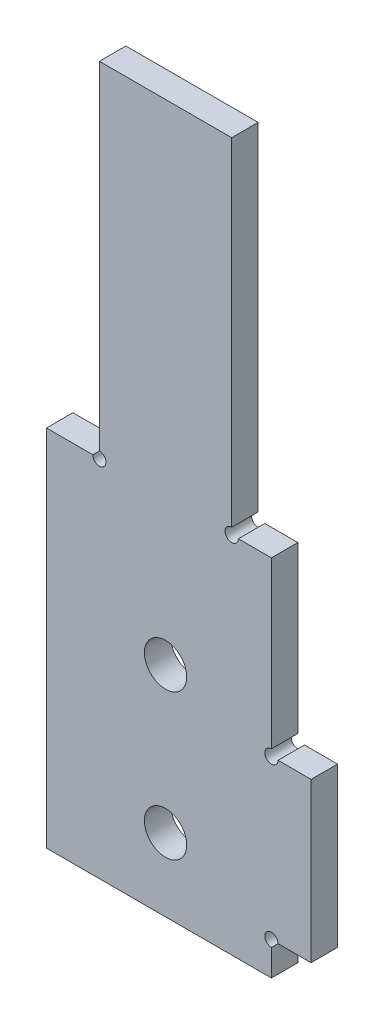
from build123d import *

# Parameters (mm, degrees)
EXTRUDE_1_DEPTH     = 2
SKETCH_2_R          = 1.6
CUT_EXTRUDE_1_DEPTH = 3
SKETCH_3_W          = 3
SKETCH_3_H          = 24
SKETCH_3_W_2        = 4
CUT_EXTRUDE_2_DEPTH = 3
SKETCH_4_W          = 10
SKETCH_4_H          = 2
EXTRUDE_2_DEPTH     = 2
SKETCH_5_R          = 0.5
CUT_EXTRUDE_3_DEPTH = 2
SKETCH_6_R          = 0.5
CUT_EXTRUDE_4_DEPTH = 2


with BuildPart() as part:
    # 草图1 → 凸台-拉伸1 (new body)
    with BuildSketch(Plane.XY):
        Polygon((0, 0), (17, 0), (17, 2.5), (20, 2.5), (20, 14.5), (17, 14.5), (17, 51.5), (0, 51.5), align=None)
    extrude(amount=EXTRUDE_1_DEPTH)

    # 草图2 → 切除-拉伸1 (cut, through all)
    with BuildSketch(Plane.XY.offset(2)):
        with Locations((9, 5.5)):
            Circle(SKETCH_2_R)
        with Locations((9, 16.5)):
            Circle(SKETCH_2_R)
    extrude(amount=-CUT_EXTRUDE_1_DEPTH, mode=Mode.SUBTRACT)

    # 草图3 → 切除-拉伸2 (cut, through all)
    with BuildSketch(Plane.XY.offset(2)):
        with Locations((15.5, 39.5)):
            Rectangle(SKETCH_3_W, SKETCH_3_H)
        with Locations((2, 39.5)):
            Rectangle(SKETCH_3_W_2, SKETCH_3_H)
    extrude(amount=-CUT_EXTRUDE_2_DEPTH, mode=Mode.SUBTRACT)

    # 草图4 → 凸台-拉伸2 (add)
    with BuildSketch(Plane(origin=(0, 51.5, 0), x_dir=(1, 0, 0), z_dir=(0, 1, 0))):
        with Locations((9, -1)):
            Rectangle(SKETCH_4_W, SKETCH_4_H)
    extrude(amount=EXTRUDE_2_DEPTH)

    # 草图5 → 切除-拉伸3 (cut)
    with BuildSketch(Plane(origin=(0, 0, 0), x_dir=(-1, 0, 0), z_dir=(0, 0, -1))):
        with Locations((-14, 27.5)):
            Circle(SKETCH_5_R)
        with Locations((-4, 27.5)):
            Circle(SKETCH_5_R)
    extrude(amount=-CUT_EXTRUDE_3_DEPTH, mode=Mode.SUBTRACT)

    # 草图6 → 切除-拉伸4 (cut)
    with BuildSketch(Plane(origin=(0, 0, 0), x_dir=(-1, 0, 0), z_dir=(0, 0, -1))):
        with Locations((-17, 14.5)):
            Circle(SKETCH_6_R)
        with Locations((-17, 2.5)):
            Circle(SKETCH_6_R)
    extrude(amount=-CUT_EXTRUDE_4_DEPTH, mode=Mode.SUBTRACT)


solid = part.part
